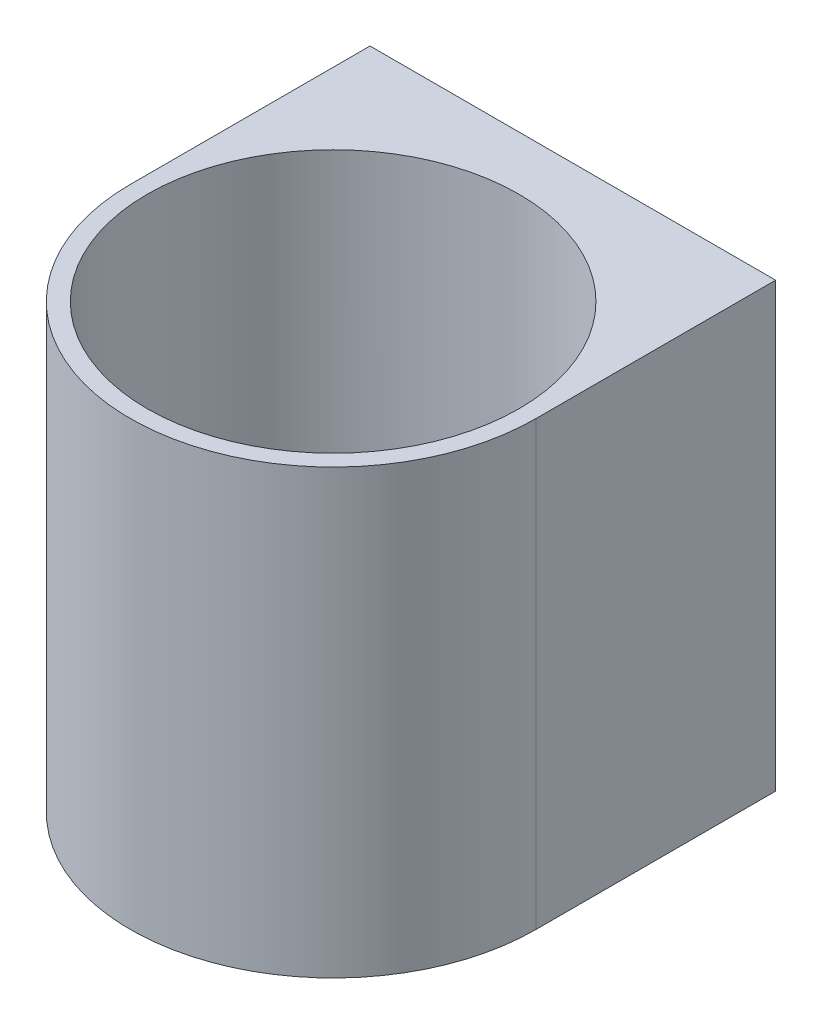
from build123d import *

# Parameters (mm, degrees)
SKETCH1_R           = 25.2
BOSS_EXTRUDE2_DEPTH = 60
SKETCH3_R           = 25.2
BOSS_EXTRUDE3_DEPTH = 9.3
SKETCH4_R           = 3.5
CUT_EXTRUDE1_DEPTH  = 9.3


with BuildPart() as part:
    # Sketch1 → Boss-Extrude2 (new body)
    with BuildSketch(Plane(origin=(0, 0, 0), x_dir=(1, 0, 0), z_dir=(0, 1, 0))):
        with BuildLine():
            Line((9.493421053, 16.463815789), (-45.506578947, 16.463815789))
            Line((-45.506578947, 16.463815789), (-45.506578947, -16.036184211))
            ThreePointArc((-45.506578947, -16.036184211), (-18.006578947, -43.536184211), (9.493421053, -16.036184211))
            Line((9.493421053, -16.036184211), (9.493421053, 16.463815789))
        make_face()
        with Locations((-18.006578947, -16.036184211)):
            Circle(SKETCH1_R, mode=Mode.SUBTRACT)
    extrude(amount=BOSS_EXTRUDE2_DEPTH)

    # Sketch3 → Boss-Extrude3 (add)
    with BuildSketch(Plane(origin=(0, 0, 0), x_dir=(-1, 0, 0), z_dir=(0, -1, 0))):
        with Locations((18.006578947, -16.036184211)):
            Circle(SKETCH3_R)
    extrude(amount=-BOSS_EXTRUDE3_DEPTH)

    # Sketch4 → Cut-Extrude1 (cut)
    with BuildSketch(Plane(origin=(0, 9.3, 0), x_dir=(1, 0, 0), z_dir=(0, 1, 0))):
        with BuildLine():
            ThreePointArc((-18.006578947, 7.463815789), (-21.506578947, 3.963815789), (-18.006578947, 0.463815789))
            Line((-18.006578947, 0.463815789), (-18.006578947, 7.463815789))
        make_face()
        with BuildLine():
            Line((-18.006578947, 7.463815789), (-18.006578947, 0.463815789))
            ThreePointArc((-18.006578947, 0.463815789), (-15.531705213, 1.488942055), (-14.506578947, 3.963815789))
            ThreePointArc((-14.506578947, 3.963815789), (-15.531705213, 6.438689524), (-18.006578947, 7.463815789))
        make_face()
        with BuildLine():
            ThreePointArc((-18.006578947, -2.536184211), (-21.506578947, -6.036184211), (-18.006578947, -9.536184211))
            Line((-18.006578947, -9.536184211), (-18.006578947, -2.536184211))
        make_face()
        with BuildLine():
            Line((-18.006578947, -2.536184211), (-18.006578947, -9.536184211))
            ThreePointArc((-18.006578947, -9.536184211), (-15.531705213, -8.511057945), (-14.506578947, -6.036184211))
            ThreePointArc((-14.506578947, -6.036184211), (-15.531705213, -3.561310476), (-18.006578947, -2.536184211))
        make_face()
        with Locations((-28.006578947, -6.036184211)):
            Circle(SKETCH4_R)
        with Locations((-8.006578947, -6.036184211)):
            Circle(SKETCH4_R)
        with BuildLine():
            ThreePointArc((-4.506578947, -16.036184211), (-8.006578947, -12.536184211), (-11.506578947, -16.036184211))
            Line((-11.506578947, -16.036184211), (-4.506578947, -16.036184211))
        make_face()
        with BuildLine():
            Line((-4.506578947, -16.036184211), (-11.506578947, -16.036184211))
            ThreePointArc((-11.506578947, -16.036184211), (-8.006578947, -19.536184211), (-4.506578947, -16.036184211))
        make_face()
        with BuildLine():
            ThreePointArc((5.493421053, -16.036184211), (1.993421053, -12.536184211), (-1.506578947, -16.036184211))
            Line((-1.506578947, -16.036184211), (5.493421053, -16.036184211))
        make_face()
        with BuildLine():
            Line((5.493421053, -16.036184211), (-1.506578947, -16.036184211))
            ThreePointArc((-1.506578947, -16.036184211), (1.993421053, -19.536184211), (5.493421053, -16.036184211))
        make_face()
        with BuildLine():
            ThreePointArc((-21.506578947, -16.036184211), (-20.481452682, -18.511057945), (-18.006578947, -19.536184211))
            Line((-18.006578947, -19.536184211), (-18.006578947, -16.036184211))
            Line((-18.006578947, -16.036184211), (-21.506578947, -16.036184211))
        make_face()
        with BuildLine():
            Line((-18.006578947, -16.036184211), (-18.006578947, -19.536184211))
            ThreePointArc((-18.006578947, -19.536184211), (-15.531705213, -18.511057945), (-14.506578947, -16.036184211))
            Line((-14.506578947, -16.036184211), (-18.006578947, -16.036184211))
        make_face()
        with BuildLine():
            Line((-21.506578947, -16.036184211), (-18.006578947, -16.036184211))
            Line((-18.006578947, -16.036184211), (-18.006578947, -12.536184211))
            ThreePointArc((-18.006578947, -12.536184211), (-20.481452682, -13.561310476), (-21.506578947, -16.036184211))
        make_face()
        with BuildLine():
            Line((-18.006578947, -12.536184211), (-18.006578947, -16.036184211))
            Line((-18.006578947, -16.036184211), (-14.506578947, -16.036184211))
            ThreePointArc((-14.506578947, -16.036184211), (-15.531705213, -13.561310476), (-18.006578947, -12.536184211))
        make_face()
        with BuildLine():
            ThreePointArc((-41.506578947, -16.036184211), (-38.006578947, -19.536184211), (-34.506578947, -16.036184211))
            Line((-34.506578947, -16.036184211), (-41.506578947, -16.036184211))
        make_face()
        with BuildLine():
            Line((-41.506578947, -16.036184211), (-34.506578947, -16.036184211))
            ThreePointArc((-34.506578947, -16.036184211), (-38.006578947, -12.536184211), (-41.506578947, -16.036184211))
        make_face()
        with Locations((-28.006578947, -26.036184211)):
            Circle(SKETCH4_R)
        with BuildLine():
            ThreePointArc((-18.006578947, -22.536184211), (-21.506578947, -26.036184211), (-18.006578947, -29.536184211))
            Line((-18.006578947, -29.536184211), (-18.006578947, -22.536184211))
        make_face()
        with BuildLine():
            Line((-18.006578947, -22.536184211), (-18.006578947, -29.536184211))
            ThreePointArc((-18.006578947, -29.536184211), (-15.531705213, -28.511057945), (-14.506578947, -26.036184211))
            ThreePointArc((-14.506578947, -26.036184211), (-15.531705213, -23.561310476), (-18.006578947, -22.536184211))
        make_face()
        with Locations((-8.006578947, -26.036184211)):
            Circle(SKETCH4_R)
        with BuildLine():
            ThreePointArc((-18.006578947, -32.536184211), (-21.506578947, -36.036184211), (-18.006578947, -39.536184211))
            Line((-18.006578947, -39.536184211), (-18.006578947, -32.536184211))
        make_face()
        with BuildLine():
            Line((-18.006578947, -32.536184211), (-18.006578947, -39.536184211))
            ThreePointArc((-18.006578947, -39.536184211), (-15.531705213, -38.511057945), (-14.506578947, -36.036184211))
            ThreePointArc((-14.506578947, -36.036184211), (-15.531705213, -33.561310476), (-18.006578947, -32.536184211))
        make_face()
        with BuildLine():
            ThreePointArc((-31.506578947, -16.036184211), (-28.006578947, -19.536184211), (-24.506578947, -16.036184211))
            Line((-24.506578947, -16.036184211), (-31.506578947, -16.036184211))
        make_face()
        with BuildLine():
            Line((-31.506578947, -16.036184211), (-24.506578947, -16.036184211))
            ThreePointArc((-24.506578947, -16.036184211), (-28.006578947, -12.536184211), (-31.506578947, -16.036184211))
        make_face()
    extrude(amount=-CUT_EXTRUDE1_DEPTH, mode=Mode.SUBTRACT)


solid = part.part
